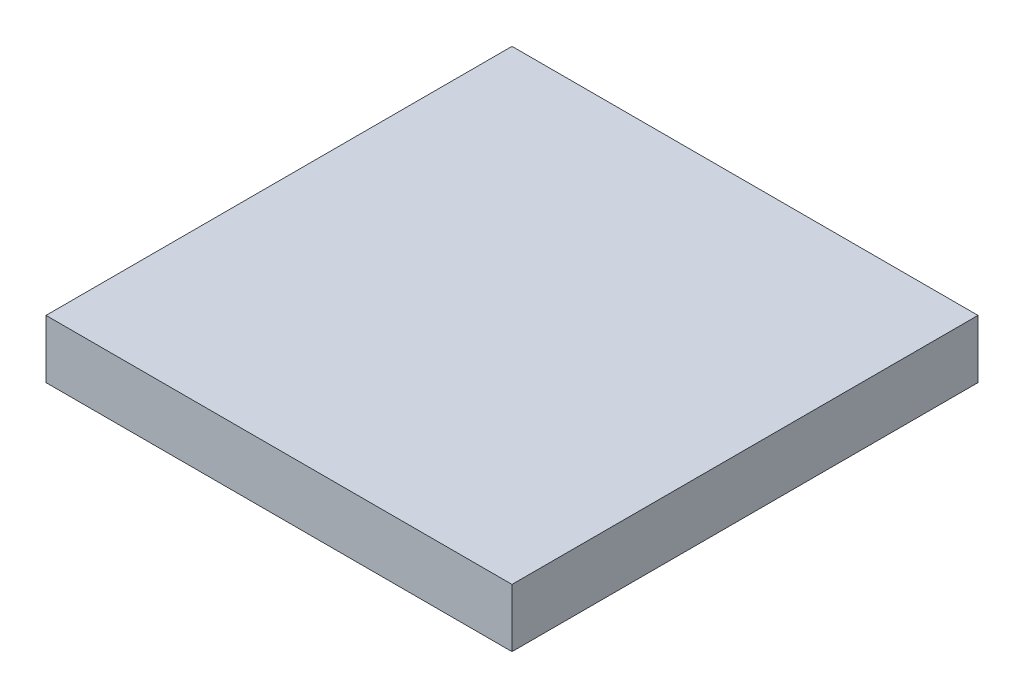
from build123d import *

# Parameters (mm, degrees)
SKETCH1_W           = 25.4
SKETCH1_H           = 25.4
BOSS_EXTRUDE1_DEPTH = 3.175
SKETCH2_R           = 0.79375
SKETCH2_W           = 3.175
SKETCH2_H           = 3.175
CUT_EXTRUDE1_DEPTH  = 1.5875


with BuildPart() as part:
    # Sketch1 → Boss-Extrude1 (new body)
    with BuildSketch(Plane(origin=(0, 0, 0), x_dir=(1, 0, 0), z_dir=(0, 1, 0))):
        Rectangle(SKETCH1_W, SKETCH1_H)
    extrude(amount=BOSS_EXTRUDE1_DEPTH)

    # Sketch2 → Cut-Extrude1 (cut)
    with BuildSketch(Plane.XZ):
        with Locations((-11.1125, -1.5875)):
            Circle(SKETCH2_R)
        with Locations((-11.1125, 1.5875)):
            Circle(SKETCH2_R)
        with Locations((-7.9375, 1.5875)):
            Circle(SKETCH2_R)
        with Locations((-7.9375, -1.5875)):
            Circle(SKETCH2_R)
        with Locations((4.181434671, 10.4174573)):
            Circle(SKETCH2_R)
        with Locations((6.931065329, 8.8299573)):
            Circle(SKETCH2_R)
        with Locations((5.343565329, 6.080326643)):
            Circle(SKETCH2_R)
        with Locations((2.593934671, 7.667826643)):
            Circle(SKETCH2_R)
        with Locations((6.931065329, -8.8299573)):
            Circle(SKETCH2_R)
        with Locations((4.181434671, -10.4174573)):
            Circle(SKETCH2_R)
        with Locations((2.593934671, -7.667826643)):
            Circle(SKETCH2_R)
        with Locations((5.343565329, -6.080326643)):
            Circle(SKETCH2_R)
        with Locations((-9.525, 0)):
            Rectangle(SKETCH2_W, SKETCH2_H)
        Polygon((6.931065329, 8.8299573), (4.181434671, 10.4174573), (2.593934671, 7.667826643), (5.343565329, 6.080326643), align=None)
        Polygon((4.181434671, -10.4174573), (6.931065329, -8.8299573), (5.343565329, -6.080326643), (2.593934671, -7.667826643), align=None)
    extrude(amount=-CUT_EXTRUDE1_DEPTH, mode=Mode.SUBTRACT)


solid = part.part
